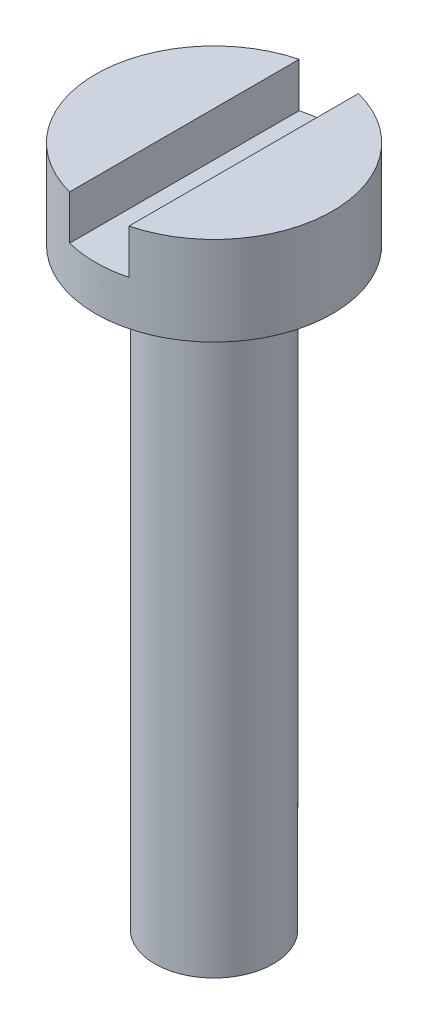
from build123d import *

# Parameters (mm, degrees)
SKETCH1_R          = 4
EXTRUDE1_DEPTH     = 3
CUT_EXTRUDE1_DEPTH = 1.5
SKETCH3_R          = 2
EXTRUDE2_DEPTH     = 20


with BuildPart() as part:
    # Sketch1 → Extrude1 (new body)
    with BuildSketch(Plane(origin=(0, 0, 0), x_dir=(1, 0, 0), z_dir=(0, 1, 0))):
        with Locations(Location((0, 0, 0), (0, 0, 270))):  # turned: the seam where the file's is
            Circle(SKETCH1_R)
    extrude(amount=EXTRUDE1_DEPTH)

    # Sketch2 → Cut-Extrude1 (cut)
    with BuildSketch(Plane(origin=(0, 3, 0), x_dir=(-1, 0, 0), z_dir=(0, 1, 0))):
        Polygon((0, 4.401224563), (-1, 4.401224563), (-1, -5.078336035), (1, -5.078336035), (1, 4.401224563), align=None)
    extrude(amount=-CUT_EXTRUDE1_DEPTH, mode=Mode.SUBTRACT)

    # Sketch3 → Extrude2 (add)
    with BuildSketch(Plane.XZ):
        with Locations(Location((0, 0, 0), (0, 0, 90))):  # turned: the seam where the file's is
            Circle(SKETCH3_R)
    extrude(amount=EXTRUDE2_DEPTH)


solid = part.part
